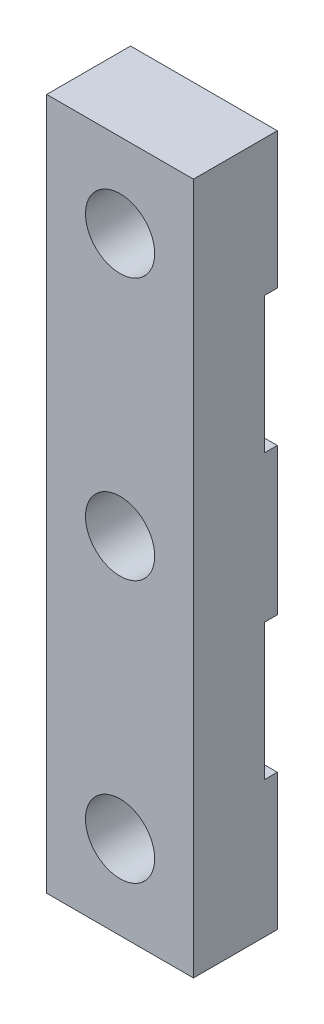
from build123d import *

# Parameters (mm, degrees)
ESBO_O1_W                = 7
ESBO_O1_H                = 33
ESBO_O1_R                = 1.65
RESSALTO_EXTRUS_O1_DEPTH = 4
ESBO_O2_W                = 0.6
ESBO_O2_H                = 6.5
CORTE_EXTRUS_O1_DEPTH    = 8


with BuildPart() as part:
    # Esboço1 → Ressalto-extrusão1 (new body)
    with BuildSketch(Plane.XY):
        Rectangle(ESBO_O1_W, ESBO_O1_H)
        Circle(ESBO_O1_R, mode=Mode.SUBTRACT)
        with Locations((0, 12.5)):
            Circle(ESBO_O1_R, mode=Mode.SUBTRACT)
        with Locations((0, -12.5)):
            Circle(ESBO_O1_R, mode=Mode.SUBTRACT)
    extrude(amount=RESSALTO_EXTRUS_O1_DEPTH)

    # Esboço2 → Corte-extrusão1 (cut, through all)
    with BuildSketch(Plane.ZY.offset(3.5)):
        with Locations((0.3, 6.75)):
            Rectangle(ESBO_O2_W, ESBO_O2_H)
        with Locations((0.3, -6.75)):
            Rectangle(ESBO_O2_W, ESBO_O2_H)
    extrude(amount=-CORTE_EXTRUS_O1_DEPTH, mode=Mode.SUBTRACT)


solid = part.part
